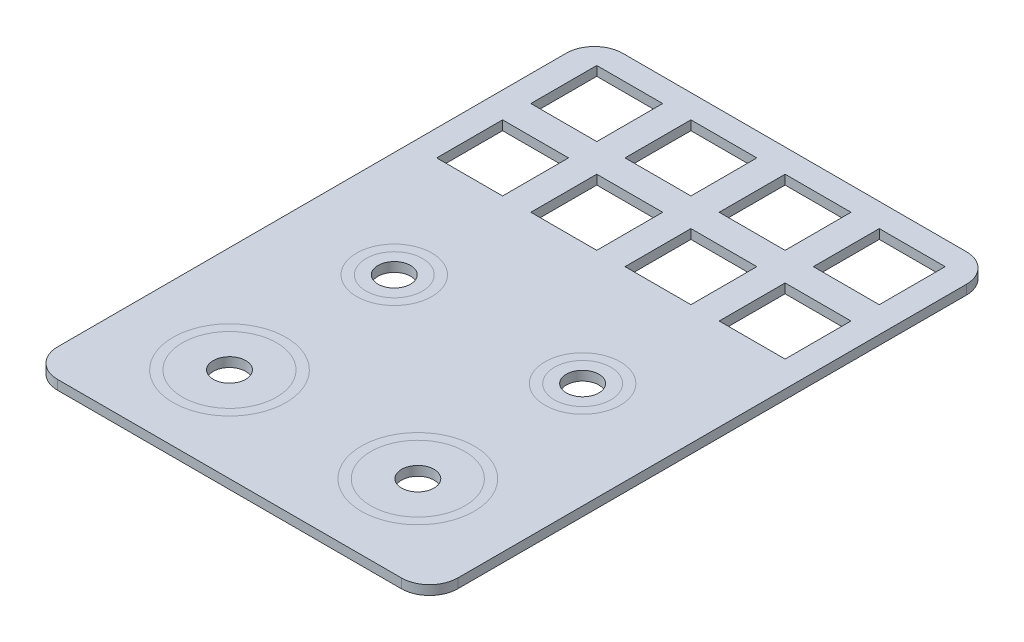
from build123d import *

# Parameters (mm, degrees)
ESQUISSE1_W             = 85
ESQUISSE1_H             = 120
BOSS_EXTRU_1_DEPTH      = 2
ESQUISSE2_W             = 14
ESQUISSE2_H             = 14
ENL_V_MAT_EXTRU_1_DEPTH = 2
ESQUISSE3_R             = 8
ESQUISSE3_R_2           = 12
ENL_V_MAT_EXTRU_2_DEPTH = 2
CONG_1_R                = 6
ESQUISSE4_R             = 8
ESQUISSE4_R_2           = 6
BOSS_EXTRU_2_DEPTH      = 2
ESQUISSE4_R_3           = 12
ESQUISSE4_R_4           = 10
BOSS_EXTRU_2_2_DEPTH    = 2
BOSS_EXTRU_2_3_DEPTH    = 2
BOSS_EXTRU_2_4_DEPTH    = 2
ESQUISSE5_R             = 10
ESQUISSE5_R_2           = 3.45
BOSS_EXTRU_4_DEPTH      = 2
BOSS_EXTRU_4_2_DEPTH    = 2
ESQUISSE5_R_3           = 6
BOSS_EXTRU_4_3_DEPTH    = 2
BOSS_EXTRU_4_4_DEPTH    = 2


with BuildPart() as part:
    # Esquisse1 → Boss.-Extru.1 (new body)
    with BuildSketch(Plane(origin=(0, 0, 0), x_dir=(1, 0, 0), z_dir=(0, 1, 0))):
        Rectangle(ESQUISSE1_W, ESQUISSE1_H)
    extrude(amount=BOSS_EXTRU_1_DEPTH)

    # Esquisse2 → Enlèv. mat.-Extru.1 (cut)
    with BuildSketch(Plane(origin=(0, 2, 0), x_dir=(1, 0, 0), z_dir=(0, 1, 0))):
        with Locations((-30, 48)):
            Rectangle(ESQUISSE2_W, ESQUISSE2_H)
        with Locations((-10, 48)):
            Rectangle(ESQUISSE2_W, ESQUISSE2_H)
        with Locations((10, 48)):
            Rectangle(ESQUISSE2_W, ESQUISSE2_H)
        with Locations((30, 48)):
            Rectangle(ESQUISSE2_W, ESQUISSE2_H)
        with Locations((30, 28)):
            Rectangle(ESQUISSE2_W, ESQUISSE2_H)
        with Locations((10, 28)):
            Rectangle(ESQUISSE2_W, ESQUISSE2_H)
        with Locations((-10, 28)):
            Rectangle(ESQUISSE2_W, ESQUISSE2_H)
        with Locations((-30, 28)):
            Rectangle(ESQUISSE2_W, ESQUISSE2_H)
    extrude(amount=-ENL_V_MAT_EXTRU_1_DEPTH, mode=Mode.SUBTRACT)

    # Esquisse3 → Enlèv. mat.-Extru.2 (cut)
    with BuildSketch(Plane(origin=(0, 2, 0), x_dir=(1, 0, 0), z_dir=(0, 1, 0))):
        with Locations((-20, -5)):
            Circle(ESQUISSE3_R)
        with Locations((-20, -40)):
            Circle(ESQUISSE3_R_2)
        with Locations((20, -5)):
            Circle(ESQUISSE3_R)
        with Locations((20, -40)):
            Circle(ESQUISSE3_R_2)
    extrude(amount=-ENL_V_MAT_EXTRU_2_DEPTH, mode=Mode.SUBTRACT)

    # Congé1
    cong_1_edges = [part.edges().sort_by_distance(p)[0] for p in [
        (42.5, 1, 60),
        (-42.5, 1, 60),
        (-42.5, 1, -60),
        (42.5, 1, -60),
    ]]
    fillet(cong_1_edges, radius=CONG_1_R)


with BuildPart() as body_2:
    # Esquisse4 → Boss.-Extru.2 (new body)
    with BuildSketch(Plane(origin=(0, 2, 0), x_dir=(1, 0, 0), z_dir=(0, 1, 0))):
        with Locations((-20, -5)):
            Circle(ESQUISSE4_R)
        with Locations((-20, -5)):
            Circle(ESQUISSE4_R_2, mode=Mode.SUBTRACT)
    extrude(amount=-BOSS_EXTRU_2_DEPTH)


with BuildPart() as body_3:
    # Esquisse4 → Boss.-Extru.2 2 (new body)
    with BuildSketch(Plane(origin=(0, 2, 0), x_dir=(1, 0, 0), z_dir=(0, 1, 0))):
        with Locations((-20, -40)):
            Circle(ESQUISSE4_R_3)
        with Locations((-20, -40)):
            Circle(ESQUISSE4_R_4, mode=Mode.SUBTRACT)
    extrude(amount=-BOSS_EXTRU_2_2_DEPTH)


with BuildPart() as body_4:
    # Esquisse4 → Boss.-Extru.2 3 (new body)
    with BuildSketch(Plane(origin=(0, 2, 0), x_dir=(1, 0, 0), z_dir=(0, 1, 0))):
        with Locations((20, -40)):
            Circle(ESQUISSE4_R_3)
        with Locations((20, -40)):
            Circle(ESQUISSE4_R_4, mode=Mode.SUBTRACT)
    extrude(amount=-BOSS_EXTRU_2_3_DEPTH)


with BuildPart() as body_5:
    # Esquisse4 → Boss.-Extru.2 4 (new body)
    with BuildSketch(Plane(origin=(0, 2, 0), x_dir=(1, 0, 0), z_dir=(0, 1, 0))):
        with Locations((20, -5)):
            Circle(ESQUISSE4_R)
        with Locations((20, -5)):
            Circle(ESQUISSE4_R_2, mode=Mode.SUBTRACT)
    extrude(amount=-BOSS_EXTRU_2_4_DEPTH)


with BuildPart() as body_6:
    # Esquisse5 → Boss.-Extru.4 (new body)
    with BuildSketch(Plane(origin=(0, 2, 0), x_dir=(1, 0, 0), z_dir=(0, 1, 0))):
        with Locations((-20, -40)):
            Circle(ESQUISSE5_R)
        with Locations((-20, -40)):
            Circle(ESQUISSE5_R_2, mode=Mode.SUBTRACT)
    extrude(amount=-BOSS_EXTRU_4_DEPTH)


with BuildPart() as body_7:
    # Esquisse5 → Boss.-Extru.4 2 (new body)
    with BuildSketch(Plane(origin=(0, 2, 0), x_dir=(1, 0, 0), z_dir=(0, 1, 0))):
        with Locations((20, -40)):
            Circle(ESQUISSE5_R)
        with Locations((20, -40)):
            Circle(ESQUISSE5_R_2, mode=Mode.SUBTRACT)
    extrude(amount=-BOSS_EXTRU_4_2_DEPTH)


with BuildPart() as body_8:
    # Esquisse5 → Boss.-Extru.4 3 (new body)
    with BuildSketch(Plane(origin=(0, 2, 0), x_dir=(1, 0, 0), z_dir=(0, 1, 0))):
        with Locations((20, -5)):
            Circle(ESQUISSE5_R_3)
        with Locations((20, -5)):
            Circle(ESQUISSE5_R_2, mode=Mode.SUBTRACT)
    extrude(amount=-BOSS_EXTRU_4_3_DEPTH)


with BuildPart() as body_9:
    # Esquisse5 → Boss.-Extru.4 4 (new body)
    with BuildSketch(Plane(origin=(0, 2, 0), x_dir=(1, 0, 0), z_dir=(0, 1, 0))):
        with Locations((-20, -5)):
            Circle(ESQUISSE5_R_3)
        with Locations((-20, -5)):
            Circle(ESQUISSE5_R_2, mode=Mode.SUBTRACT)
    extrude(amount=-BOSS_EXTRU_4_4_DEPTH)


solid = Compound([part.part, body_2.part, body_3.part, body_4.part, body_5.part, body_6.part, body_7.part, body_8.part, body_9.part])
